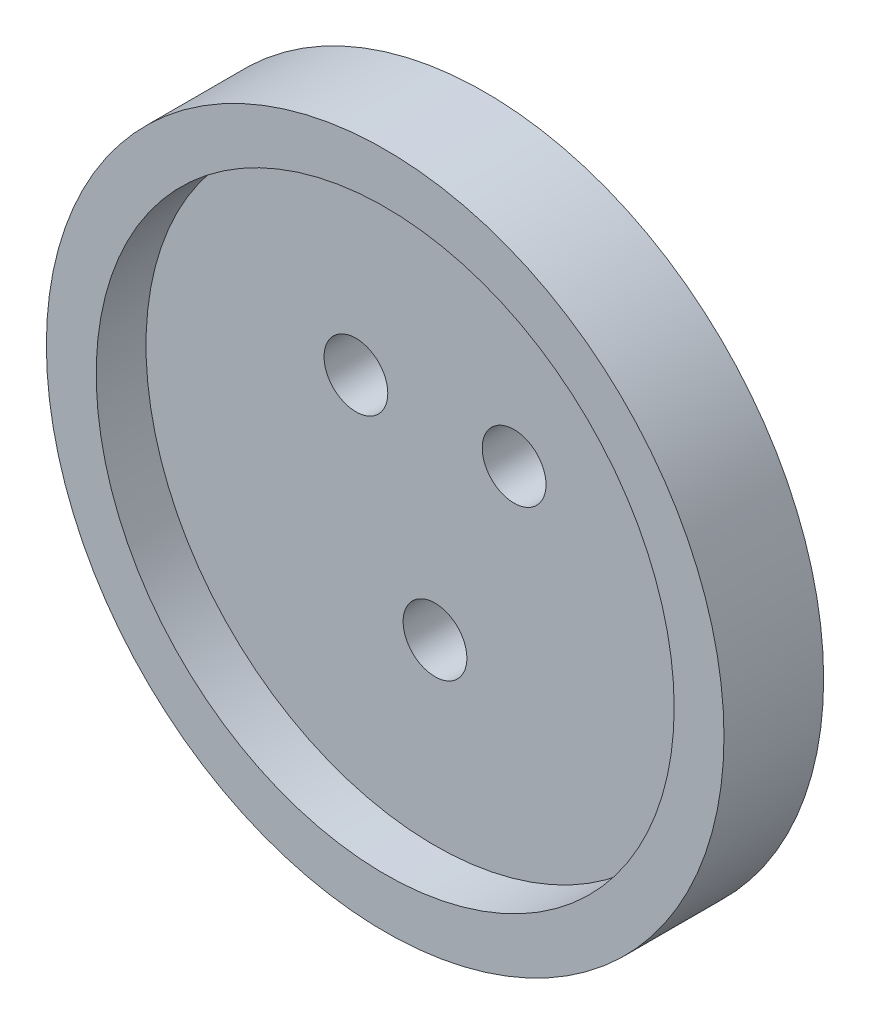
from build123d import *

# Parameters (mm, degrees)
SKETCH1_R      = 24
EXTRUDE1_DEPTH = 4
SKETCH2_R      = 24
EXTRUDE2_DEPTH = 1
SKETCH3_R      = 3.2
EXTRUDE3_DEPTH = 6
SKETCH4_R      = 34
SKETCH4_R_2    = 24
EXTRUDE4_DEPTH = 5
SKETCH5_R      = 34
SKETCH5_R_2    = 29
EXTRUDE5_DEPTH = 5


with BuildPart() as part:
    # Sketch1 → Extrude1 (new body)
    with BuildSketch(Plane.XY):
        Circle(SKETCH1_R)
    extrude(amount=EXTRUDE1_DEPTH)

    # Sketch2 → Extrude2 (add)
    with BuildSketch(Plane.XY.offset(4)):
        Circle(SKETCH2_R)
    extrude(amount=EXTRUDE2_DEPTH)

    # Sketch3 → Extrude3 (cut, through all)
    with BuildSketch(Plane.XY.offset(5)):
        with Locations((-7.9375, 7.9375)):
            Circle(SKETCH3_R)
        with Locations((7.9375, 7.9375)):
            Circle(SKETCH3_R)
        with Locations((0, -11.1125)):
            Circle(SKETCH3_R)
    extrude(amount=-EXTRUDE3_DEPTH, mode=Mode.SUBTRACT)

    # Sketch4 → Extrude4 (add)
    with BuildSketch(Plane(origin=(0, 0, 0), x_dir=(-1, 0, 0), z_dir=(0, 0, -1))):
        Circle(SKETCH4_R)
        Circle(SKETCH4_R_2, mode=Mode.SUBTRACT)
    extrude(amount=-EXTRUDE4_DEPTH)

    # Sketch5 → Extrude5 (add)
    with BuildSketch(Plane.XY.offset(5)):
        Circle(SKETCH5_R)
        Circle(SKETCH5_R_2, mode=Mode.SUBTRACT)
    extrude(amount=EXTRUDE5_DEPTH)


solid = part.part
